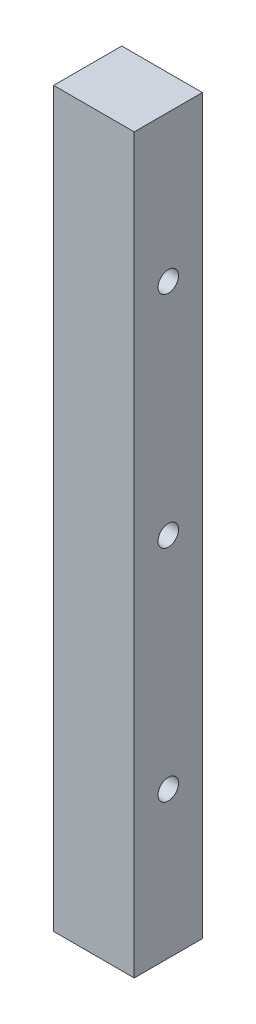
from build123d import *

# Parameters (mm, degrees)
SKETCH1_W           = 13.97
SKETCH1_H           = 127
BOSS_EXTRUDE1_DEPTH = 11.811
SKETCH2_R           = 1.778
CUT_EXTRUDE1_DEPTH  = 14.97


with BuildPart() as part:
    # Sketch1 → Boss-Extrude1 (new body)
    with BuildSketch(Plane.XY):
        with Locations((6.985, 63.5)):
            Rectangle(SKETCH1_W, SKETCH1_H)
    extrude(amount=BOSS_EXTRUDE1_DEPTH)

    # Sketch2 → Cut-Extrude1 (cut, through all)
    with BuildSketch(Plane.ZY):
        with Locations((5.9055, 101.6)):
            Circle(SKETCH2_R)
        with Locations((5.9055, 63.5)):
            Circle(SKETCH2_R)
        with Locations((5.9055, 25.4)):
            Circle(SKETCH2_R)
    extrude(amount=-CUT_EXTRUDE1_DEPTH, mode=Mode.SUBTRACT)


solid = part.part
